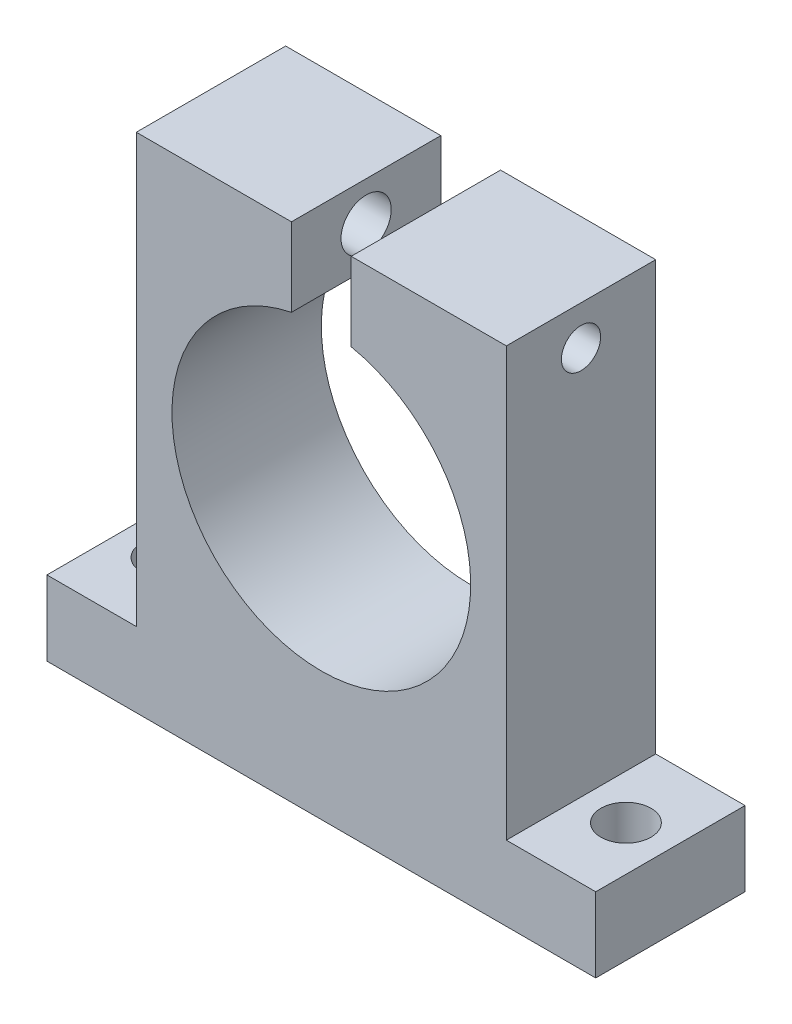
from build123d import *

# Parameters (mm, degrees)
BOSS_EXTRUDE3_DEPTH             = 9.525
TAP_DRILL_FOR_M3X0_5_TAP1_D     = 2.5
TAP_DRILL_FOR_M3X0_5_TAP1_DEPTH = 9.895
M3_CLEARANCE_HOLE1_D            = 3.2
M3_CLEARANCE_HOLE2_D            = 3.2
M3_CLEARANCE_HOLE2_DEPTH        = 4.76
M3_CLEARANCE_HOLE2_TIP          = 0.96137699
M3_CLEARANCE_HOLE3_D            = 3.2
M3_CLEARANCE_HOLE3_DEPTH        = 9.895


with BuildPart() as part:
    # Sketch7 → Boss-Extrude3 (new body)
    with BuildSketch(Plane.XY):
        with BuildLine():
            Line((-11.8, 14.33255592), (-1.905, 14.33255592))
            Line((-1.905, 14.33255592), (-1.905, 9.33255592))
            ThreePointArc((-1.905, 9.33255592), (0, -9.525), (1.905, 9.33255592))
            Line((1.905, 9.33255592), (1.905, 14.33255592))
            Line((1.905, 14.33255592), (11.8, 14.33255592))
            Line((11.8, 14.33255592), (11.8, -12.96744408))
            Line((11.8, -12.96744408), (17.5, -12.96744408))
            Line((17.5, -12.96744408), (17.5, -17.73044408))
            Line((17.5, -17.73044408), (-17.5, -17.73044408))
            Line((-17.5, -17.73044408), (-17.5, -12.96744408))
            Line((-17.5, -12.96744408), (-11.8, -12.96744408))
            Line((-11.8, -12.96744408), (-11.8, 14.33255592))
        make_face()
    extrude(amount=BOSS_EXTRUDE3_DEPTH)

    # Tap Drill for M3x0.5 Tap1
    with Locations(Plane(origin=(11.8, 0, 0), x_dir=(0, 0, -1), z_dir=(1, 0, 0))):
        with Locations((-4.7625, 11.83255592)):
            Hole(TAP_DRILL_FOR_M3X0_5_TAP1_D / 2, depth=TAP_DRILL_FOR_M3X0_5_TAP1_DEPTH)

    # M3 Clearance Hole1 (through all)
    with Locations(Plane(origin=(0, -12.96744408, 0), x_dir=(1, 0, 0), z_dir=(0, 1, 0))):
        with Locations((-14.65, -4.749621695)):
            Hole(M3_CLEARANCE_HOLE1_D / 2)

    # M3 Clearance Hole2
    with Locations(Plane(origin=(0, -12.96744408, 0), x_dir=(1, 0, 0), z_dir=(0, 1, 0))):
        with Locations((14.65, -4.749621695)):
            Hole(M3_CLEARANCE_HOLE2_D / 2, depth=M3_CLEARANCE_HOLE2_DEPTH)
            with Locations((0, 0, -(M3_CLEARANCE_HOLE2_DEPTH + M3_CLEARANCE_HOLE2_TIP / 2))):  # 118° drill point
                Cone(0, M3_CLEARANCE_HOLE2_D / 2, M3_CLEARANCE_HOLE2_TIP, mode=Mode.SUBTRACT)

    # M3 Clearance Hole3
    with Locations(Plane.ZY.offset(11.8)):
        with Locations((4.7625, 11.83255592)):
            Hole(M3_CLEARANCE_HOLE3_D / 2, depth=M3_CLEARANCE_HOLE3_DEPTH)


solid = part.part
